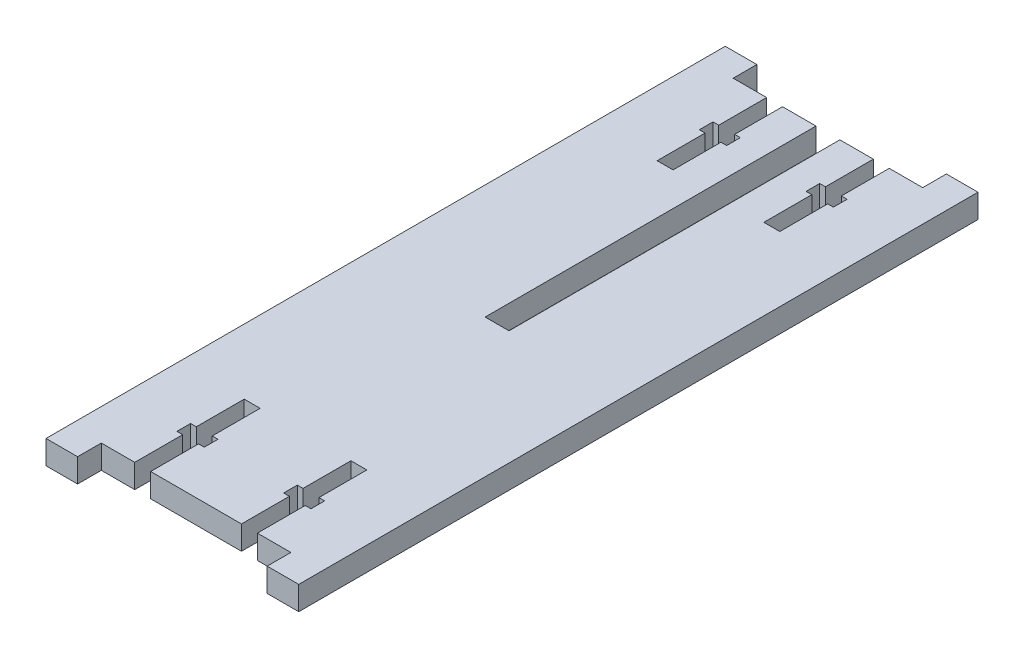
from build123d import *

# Parameters (mm, degrees)
BOSS_EXTRUDE1_DEPTH = 4.7625
SKETCH2_W           = 3.2
SKETCH2_H           = 9.625
SKETCH2_H_2         = 2.75
SKETCH2_W_2         = 1.15
CUT_EXTRUDE1_DEPTH  = 4.7625


with BuildPart() as part:
    # Sketch1 → Boss-Extrude1 (new body)
    with BuildSketch(Plane(origin=(0, 0, 0), x_dir=(1, 0, 0), z_dir=(0, 1, 0))):
        Polygon((-25.4, -63.5), (-25.4, 63.5), (-25.4, 68.2625), (-19.05, 68.2625), (-19.05, 63.5), (-2.4, 63.5), (-2.4, -3), (2.4, -3), (2.4, 63.5), (19.05, 63.5), (19.05, 68.2625), (25.4, 68.2625), (25.4, 63.5), (25.4, -63.5), (25.4, -68.2625), (19.05, -68.2625), (19.05, -63.5), (-19.05, -63.5), (-19.05, -68.2625), (-25.4, -68.2625), align=None)
    extrude(amount=BOSS_EXTRUDE1_DEPTH)

    # Sketch2 → Cut-Extrude1 (cut)
    with BuildSketch(Plane(origin=(0, 4.7625, 0), x_dir=(1, 0, 0), z_dir=(0, 1, 0))):
        with Locations((-10.725, 58.6875)):
            Rectangle(SKETCH2_W, SKETCH2_H)
        with Locations((-10.725, 52.5)):
            Rectangle(SKETCH2_W, SKETCH2_H_2)
        with Locations((-8.55, 52.5)):
            Rectangle(SKETCH2_W_2, SKETCH2_H_2)
        with Locations((-10.725, 46.3125)):
            Rectangle(SKETCH2_W, SKETCH2_H)
        with Locations((-12.9, 52.5)):
            Rectangle(SKETCH2_W_2, SKETCH2_H_2)
        with Locations((10.725, 58.6875)):
            Rectangle(SKETCH2_W, SKETCH2_H)
        with Locations((10.725, 52.5)):
            Rectangle(SKETCH2_W, SKETCH2_H_2)
        with Locations((8.55, 52.5)):
            Rectangle(SKETCH2_W_2, SKETCH2_H_2)
        with Locations((12.9, 52.5)):
            Rectangle(SKETCH2_W_2, SKETCH2_H_2)
        with Locations((10.725, 46.3125)):
            Rectangle(SKETCH2_W, SKETCH2_H)
        with Locations((-10.725, -46.3125)):
            Rectangle(SKETCH2_W, SKETCH2_H)
        with Locations((-10.725, -58.6875)):
            Rectangle(SKETCH2_W, SKETCH2_H)
        with Locations((-12.9, -52.5)):
            Rectangle(SKETCH2_W_2, SKETCH2_H_2)
        with Locations((-10.725, -52.5)):
            Rectangle(SKETCH2_W, SKETCH2_H_2)
        with Locations((-8.55, -52.5)):
            Rectangle(SKETCH2_W_2, SKETCH2_H_2)
        with Locations((10.725, -46.3125)):
            Rectangle(SKETCH2_W, SKETCH2_H)
        with Locations((8.55, -52.5)):
            Rectangle(SKETCH2_W_2, SKETCH2_H_2)
        with Locations((10.725, -52.5)):
            Rectangle(SKETCH2_W, SKETCH2_H_2)
        with Locations((12.9, -52.5)):
            Rectangle(SKETCH2_W_2, SKETCH2_H_2)
        with Locations((10.725, -58.6875)):
            Rectangle(SKETCH2_W, SKETCH2_H)
    extrude(amount=-CUT_EXTRUDE1_DEPTH, mode=Mode.SUBTRACT)


solid = part.part
